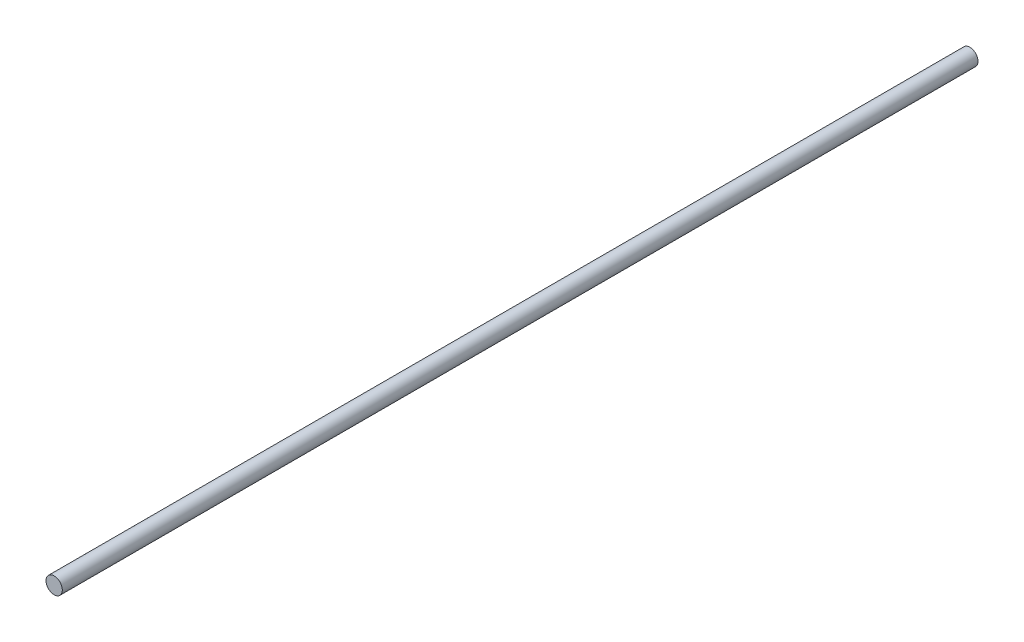
from build123d import *

# Parameters (mm, degrees)
SKETCH1_R           = 3.175
BOSS_EXTRUDE1_DEPTH = 356


with BuildPart() as part:
    # Sketch1 → Boss-Extrude1 (new body)
    with BuildSketch(Plane.XY):
        Circle(SKETCH1_R)
    extrude(amount=BOSS_EXTRUDE1_DEPTH)


solid = part.part
